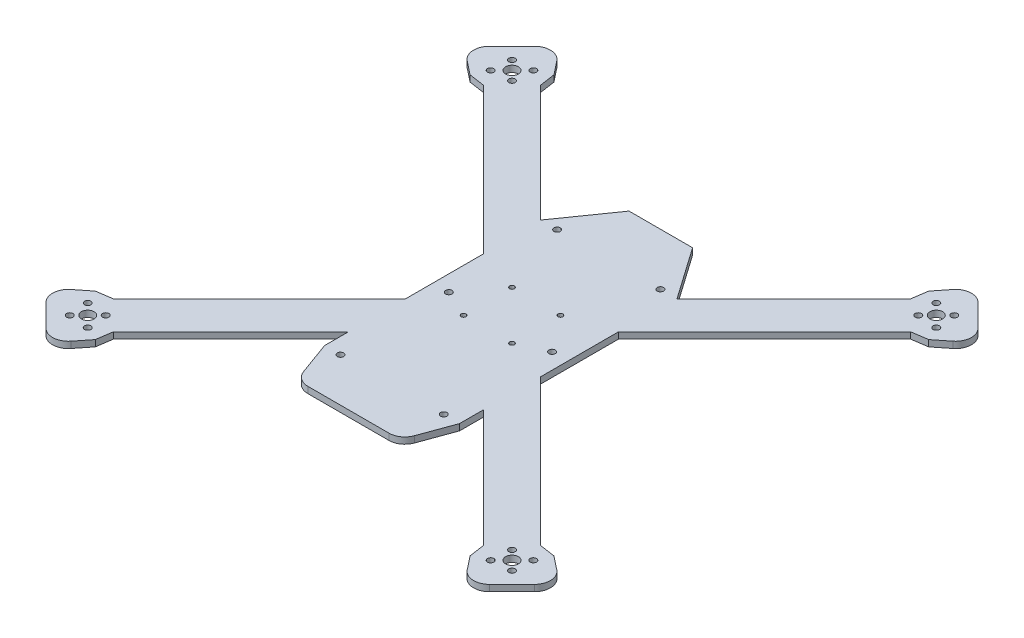
from build123d import *

# Parameters (mm, degrees)
CROQUIS1_R              = 2
CROQUIS1_R_2            = 4
CROQUIS1_R_3            = 1.5
SALIENTE_EXTRUIR1_DEPTH = 4
REDONDEO1_R             = 10


with BuildPart() as part:
    # Croquis1 → Saliente-Extruir1 (new body)
    with BuildSketch(Plane(origin=(0, 0, 0), x_dir=(1, 0, 0), z_dir=(0, 1, 0))):
        with BuildLine():
            Line((-42.5, 24.539487758), (-134.423881554, 116.463369312))
            Line((-134.423881554, 116.463369312), (-144.318030777, 117.91451064))
            Line((-144.318030777, 117.91451064), (-152.860628735, 124.671679333))
            ThreePointArc((-152.860628735, 124.671679333), (-156.639963967, 131.934164505), (-153.727896681, 139.585761057))
            Line((-153.727896681, 139.585761057), (-139.585761057, 153.727896681))
            ThreePointArc((-139.585761057, 153.727896681), (-131.934164505, 156.639963967), (-124.671679333, 152.860628735))
            Line((-124.671679333, 152.860628735), (-117.91451064, 144.318030777))
            Line((-117.91451064, 144.318030777), (-116.463369312, 134.423881554))
            Line((-116.463369312, 134.423881554), (-42.943057454, 60.903569696))
            Line((-42.943057454, 60.903569696), (-20, 93.669651468))
            Line((-20, 93.669651468), (20, 93.669651468))
            Line((20, 93.669651468), (42.943057454, 60.903569696))
            Line((42.943057454, 60.903569696), (116.463369312, 134.423881554))
            Line((116.463369312, 134.423881554), (117.91451064, 144.318030777))
            Line((117.91451064, 144.318030777), (124.671679333, 152.860628735))
            ThreePointArc((124.671679333, 152.860628735), (131.934164505, 156.639963967), (139.585761057, 153.727896681))
            Line((139.585761057, 153.727896681), (153.727896681, 139.585761057))
            ThreePointArc((153.727896681, 139.585761057), (156.639963967, 131.934164505), (152.860628735, 124.671679333))
            Line((152.860628735, 124.671679333), (144.318030777, 117.91451064))
            Line((144.318030777, 117.91451064), (134.423881554, 116.463369312))
            Line((134.423881554, 116.463369312), (42.5, 24.539487758))
            Line((42.5, 24.539487758), (42.5, -24.539487758))
            Line((42.5, -24.539487758), (134.423881554, -116.463369312))
            Line((134.423881554, -116.463369312), (144.318030777, -117.91451064))
            Line((144.318030777, -117.91451064), (152.860628735, -124.671679333))
            ThreePointArc((152.860628735, -124.671679333), (156.639963967, -131.934164505), (153.727896681, -139.585761057))
            Line((153.727896681, -139.585761057), (139.585761057, -153.727896681))
            ThreePointArc((139.585761057, -153.727896681), (131.934164505, -156.639963967), (124.671679333, -152.860628735))
            Line((124.671679333, -152.860628735), (117.91451064, -144.318030777))
            Line((117.91451064, -144.318030777), (116.463369312, -134.423881554))
            Line((116.463369312, -134.423881554), (42.5, -60.460512242))
            Line((42.5, -60.460512242), (42.5, -75.460512242))
            Line((42.5, -75.460512242), (32.5, -102.935286437))
            Line((32.5, -102.935286437), (-32.5, -102.935286437))
            Line((-32.5, -102.935286437), (-42.5, -75.460512242))
            Line((-42.5, -75.460512242), (-42.5, -60.460512242))
            Line((-42.5, -60.460512242), (-116.463369312, -134.423881554))
            Line((-116.463369312, -134.423881554), (-117.91451064, -144.318030777))
            Line((-117.91451064, -144.318030777), (-124.671679333, -152.860628735))
            ThreePointArc((-124.671679333, -152.860628735), (-131.934164505, -156.639963967), (-139.585761057, -153.727896681))
            Line((-139.585761057, -153.727896681), (-153.727896681, -139.585761057))
            ThreePointArc((-153.727896681, -139.585761057), (-156.639963967, -131.934164505), (-152.860628735, -124.671679333))
            Line((-152.860628735, -124.671679333), (-144.318030777, -117.91451064))
            Line((-144.318030777, -117.91451064), (-134.423881554, -116.463369312))
            Line((-134.423881554, -116.463369312), (-42.5, -24.539487758))
            Line((-42.5, -24.539487758), (-42.5, 24.539487758))
        make_face()
        with Locations((-127.870144559, 127.870144559)):
            Circle(CROQUIS1_R, mode=Mode.SUBTRACT)
        with Locations((-126.809484388, 140.24451323)):
            Circle(CROQUIS1_R, mode=Mode.SUBTRACT)
        with Locations((-140.24451323, 126.809484388)):
            Circle(CROQUIS1_R, mode=Mode.SUBTRACT)
        with Locations((-139.183853058, 139.183853058)):
            Circle(CROQUIS1_R, mode=Mode.SUBTRACT)
        with Locations((140.24451323, 126.809484388)):
            Circle(CROQUIS1_R, mode=Mode.SUBTRACT)
        with Locations((127.870144559, 127.870144559)):
            Circle(CROQUIS1_R, mode=Mode.SUBTRACT)
        with Locations((126.809484388, 140.24451323)):
            Circle(CROQUIS1_R, mode=Mode.SUBTRACT)
        with Locations((139.183853058, 139.183853058)):
            Circle(CROQUIS1_R, mode=Mode.SUBTRACT)
        with Locations((126.809484388, -140.24451323)):
            Circle(CROQUIS1_R, mode=Mode.SUBTRACT)
        with Locations((127.870144559, -127.870144559)):
            Circle(CROQUIS1_R, mode=Mode.SUBTRACT)
        with Locations((140.24451323, -126.809484388)):
            Circle(CROQUIS1_R, mode=Mode.SUBTRACT)
        with Locations((139.183853058, -139.183853058)):
            Circle(CROQUIS1_R, mode=Mode.SUBTRACT)
        with Locations((-140.24451323, -126.809484388)):
            Circle(CROQUIS1_R, mode=Mode.SUBTRACT)
        with Locations((-127.870144559, -127.870144559)):
            Circle(CROQUIS1_R, mode=Mode.SUBTRACT)
        with Locations((-126.809484388, -140.24451323)):
            Circle(CROQUIS1_R, mode=Mode.SUBTRACT)
        with Locations((-139.183853058, -139.183853058)):
            Circle(CROQUIS1_R, mode=Mode.SUBTRACT)
        with Locations((32.5, -75.460512242)):
            Circle(CROQUIS1_R, mode=Mode.SUBTRACT)
        with Locations((-32.5, -75.460512242)):
            Circle(CROQUIS1_R, mode=Mode.SUBTRACT)
        with Locations((-32.5, 60.907651634)):
            Circle(CROQUIS1_R, mode=Mode.SUBTRACT)
        with Locations((32.5, 60.907651634)):
            Circle(CROQUIS1_R, mode=Mode.SUBTRACT)
        with Locations((-32.5, -7.276430304)):
            Circle(CROQUIS1_R, mode=Mode.SUBTRACT)
        with Locations((32.5, -7.276430304)):
            Circle(CROQUIS1_R, mode=Mode.SUBTRACT)
        with Locations((-133.526998809, 133.526998809)):
            Circle(CROQUIS1_R_2, mode=Mode.SUBTRACT)
        with Locations((133.526998809, 133.526998809)):
            Circle(CROQUIS1_R_2, mode=Mode.SUBTRACT)
        with Locations((133.526998809, -133.526998809)):
            Circle(CROQUIS1_R_2, mode=Mode.SUBTRACT)
        with Locations((-133.526998809, -133.526998809)):
            Circle(CROQUIS1_R_2, mode=Mode.SUBTRACT)
        with Locations((15.25, 15.25)):
            Circle(CROQUIS1_R_3, mode=Mode.SUBTRACT)
        with Locations((15.25, -15.25)):
            Circle(CROQUIS1_R_3, mode=Mode.SUBTRACT)
        with Locations((-15.25, -15.25)):
            Circle(CROQUIS1_R_3, mode=Mode.SUBTRACT)
        with Locations((-15.25, 15.25)):
            Circle(CROQUIS1_R_3, mode=Mode.SUBTRACT)
    extrude(amount=SALIENTE_EXTRUIR1_DEPTH)

    # Redondeo1
    redondeo1_edges = [part.edges().sort_by_distance(p)[0] for p in [
        (32.5, 2, 102.935286437),
        (-32.5, 2, 102.935286437),
    ]]
    fillet(redondeo1_edges, radius=REDONDEO1_R)


solid = part.part
